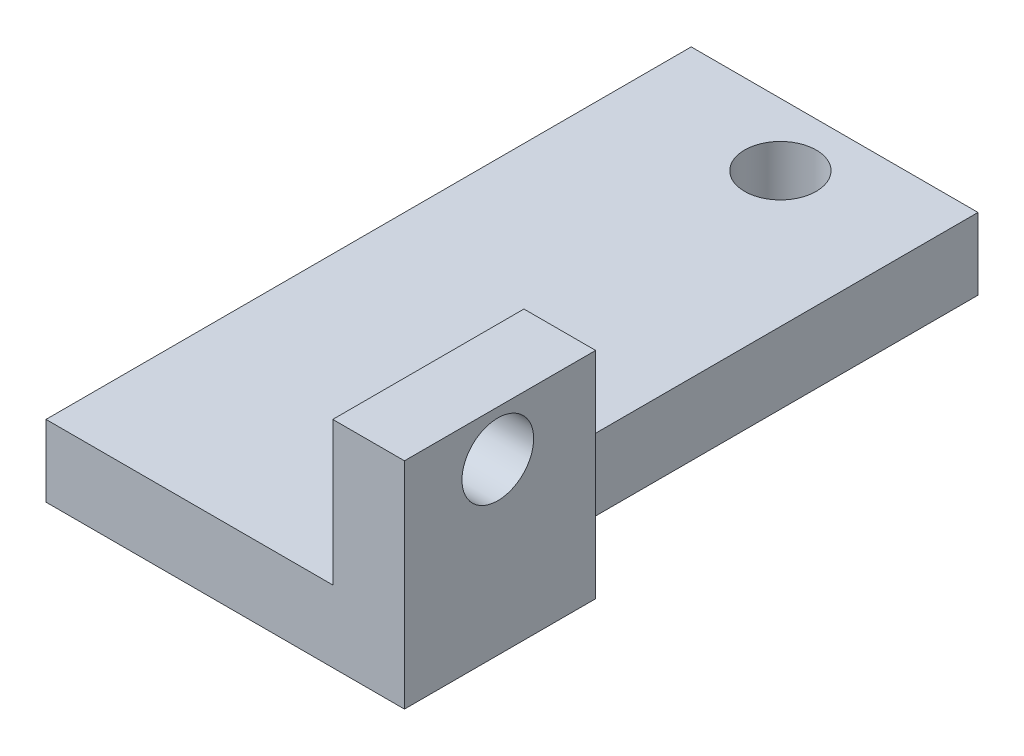
from build123d import *

# Parameters (mm, degrees)
CROQUIS1_W              = 12
CROQUIS1_H              = 27
CROQUIS1_R              = 1.5
SALIENTE_EXTRUIR2_DEPTH = 3
CROQUIS6_W              = 8
CROQUIS6_H              = 9
CROQUIS6_R              = 1.5
SALIENTE_EXTRUIR4_DEPTH = 3
ESCALA1_SCALE           = 7


with BuildPart() as part:
    # Croquis1 → Saliente-Extruir2 (new body)
    with BuildSketch(Plane(origin=(0, 0, 0), x_dir=(1, 0, 0), z_dir=(0, 1, 0))):
        with Locations((6, 13.5)):
            Rectangle(CROQUIS1_W, CROQUIS1_H)
        with Locations((6.352695101, 24.378103836)):
            Circle(CROQUIS1_R, mode=Mode.SUBTRACT)
    extrude(amount=SALIENTE_EXTRUIR2_DEPTH)

    # Croquis6 → Saliente-Extruir4 (add)
    with BuildSketch(Plane(origin=(12, 0, 0), x_dir=(0, 0, -1), z_dir=(1, 0, 0))):
        with Locations((4, 4.5)):
            Rectangle(CROQUIS6_W, CROQUIS6_H)
        with Locations((3.905842021, 7.100326765)):
            Circle(CROQUIS6_R, mode=Mode.SUBTRACT)
    extrude(amount=SALIENTE_EXTRUIR4_DEPTH)


with BuildPart() as part_1:
    # Escala1: scaled about (7.268760736, 1.961981653, -11.685014046)
    add(part.part.scale(ESCALA1_SCALE).moved(Location((-43.612564416, -11.771889918, 70.110084276))))


solid = part_1.part
